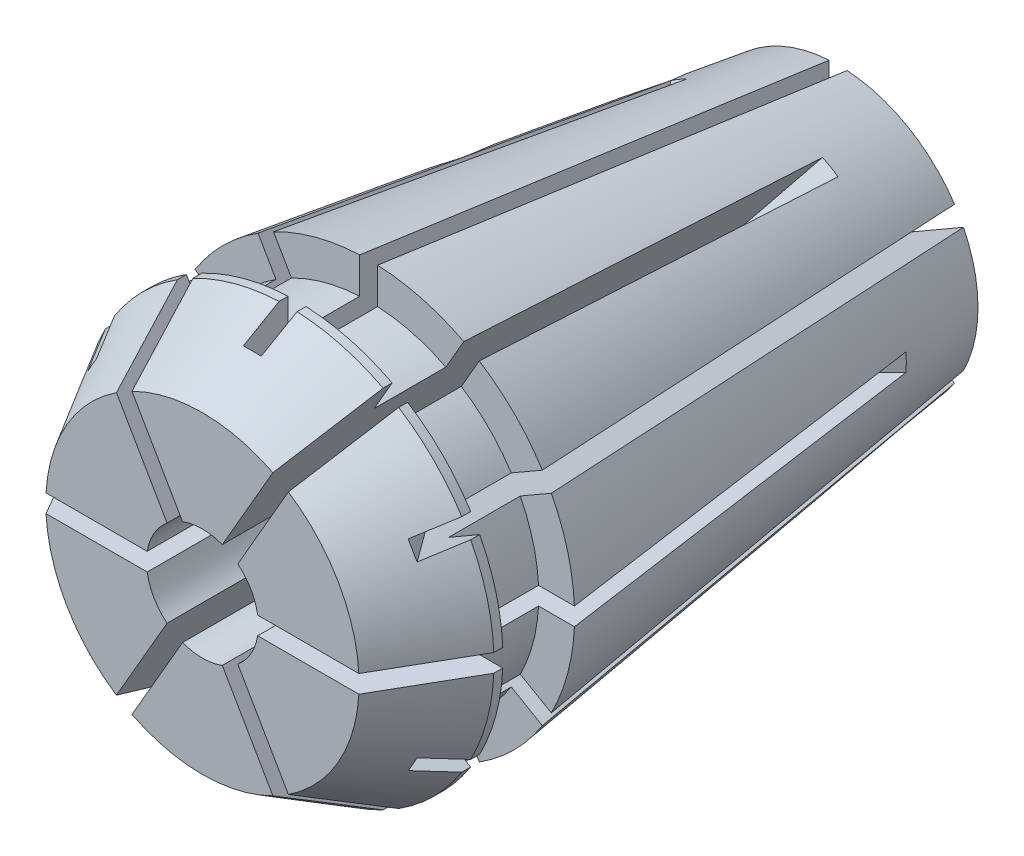
from build123d import *

# Parameters (mm, degrees)
CUT_EXTRUDE3_DEPTH = 0.254
CIRPATTERN1_COUNT  = 6
CUT_EXTRUDE4_DEPTH = 0.254
CIRPATTERN2_COUNT  = 6


with BuildPart() as part:
    # Sketch2 → Revolve1 (revolve)
    with BuildSketch(Plane(origin=(0, 0, 0), x_dir=(1, 0, 0), z_dir=(0, 1, 0))):
        Polygon((4.445, -9.017), (5.842, -6.58754254), (5.842, -6.33354254), (4.826, -6.33354254), (4.826, -4.30154254), (5.842, -4.30154254), (3.967830419, 9.017), (1.5875, 9.017), (1.5875, -9.017), align=None)
    revolve(axis=Axis((0, 0, -9.017), (0, 0, 1)))

    # Sketch3 → Cut-Extrude3 (cut, symmetric)
    with BuildSketch(Plane(origin=(0, 0, 0), x_dir=(0, 0, -1), z_dir=(1, 0, 0))):
        Polygon((-7.605911738, 5.256411738), (-7.605911738, 26.9875), (9.017, 26.9875), (9.017, 0.3175), (-2.667, 0.3175), align=None)
    cut_extrude3 = extrude(amount=CUT_EXTRUDE3_DEPTH, both=True, mode=Mode.SUBTRACT)

    # CirPattern1: Cut-Extrude3 ×6 about axis
    cirpattern1_axis = Axis((0, 0, 0), (0, 0, 1))
    for i in range(1, CIRPATTERN1_COUNT):
        add(cut_extrude3.rotate(cirpattern1_axis, i * 360 / CIRPATTERN1_COUNT), mode=Mode.SUBTRACT)

    # Sketch4 → Cut-Extrude4 (cut, symmetric)
    with BuildSketch(Plane(origin=(0, 0, 0), x_dir=(1, 0, 0), z_dir=(0, 1, 0))):
        Polygon((4.300861057, 6.650361057), (26.9875, 6.650361057), (26.9875, -9.017), (1.5875, -9.017), (0.3175, -9.017), (0.3175, 2.667), align=None)
    cut_extrude4 = extrude(amount=CUT_EXTRUDE4_DEPTH, both=True, mode=Mode.SUBTRACT)

    # CirPattern2: Cut-Extrude4 ×6 about axis
    cirpattern2_axis = Axis((0, 0, 0), (0, 0, 1))
    for i in range(1, CIRPATTERN2_COUNT):
        add(cut_extrude4.rotate(cirpattern2_axis, i * 360 / CIRPATTERN2_COUNT), mode=Mode.SUBTRACT)


solid = part.part
